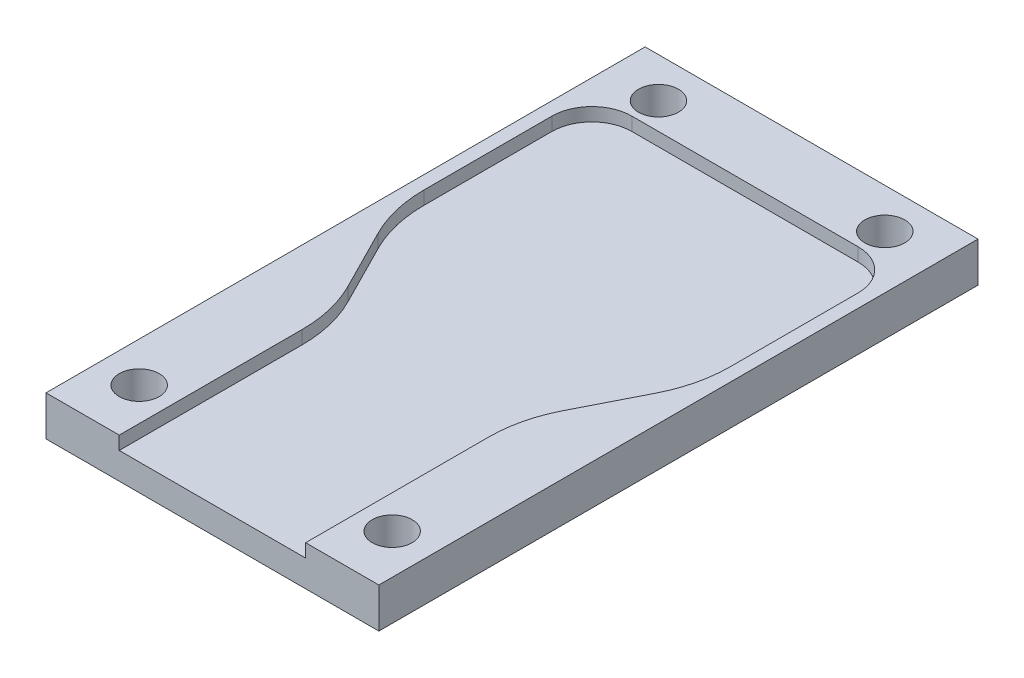
from build123d import *

# Parameters (mm, degrees)
SKETCH1_W           = 25
SKETCH1_H           = 45
BOSS_EXTRUDE1_DEPTH = 3
CUT_EXTRUDE1_DEPTH  = 1
SKETCH3_R           = 1.5
CUT_EXTRUDE2_DEPTH  = 4


with BuildPart() as part:
    # Sketch1 → Boss-Extrude1 (new body)
    with BuildSketch(Plane(origin=(0, 0, 0), x_dir=(1, 0, 0), z_dir=(0, 1, 0))):
        with Locations((12.5, 22.5)):
            Rectangle(SKETCH1_W, SKETCH1_H)
    extrude(amount=BOSS_EXTRUDE1_DEPTH)

    # Sketch2 → Cut-Extrude1 (cut)
    with BuildSketch(Plane(origin=(0, 3, 0), x_dir=(1, 0, 0), z_dir=(0, 1, 0))):
        with BuildLine():
            Line((4, 40), (21, 40))
            ThreePointArc((21, 40), (23.121320344, 39.121320344), (24, 37))
            Line((24, 37), (24, 27.390411508))
            ThreePointArc((24, 27.390411508), (23.725985305, 25.065500788), (22.918958029, 22.868002009))
            Line((22.918958029, 22.868002009), (20.581041971, 18.257235294))
            ThreePointArc((20.581041971, 18.257235294), (19.774014695, 16.059736514), (19.5, 13.734825794))
            Line((19.5, 13.734825794), (19.5, 0))
            Line((19.5, 0), (5.5, 0))
            Line((5.5, 0), (5.5, 13.734825794))
            ThreePointArc((5.5, 13.734825794), (5.225985305, 16.059736514), (4.418958029, 18.257235294))
            Line((4.418958029, 18.257235294), (2.081041971, 22.868002009))
            ThreePointArc((2.081041971, 22.868002009), (1.274014695, 25.065500788), (1, 27.390411508))
            Line((1, 27.390411508), (1, 37))
            ThreePointArc((1, 37), (1.878679656, 39.121320344), (4, 40))
        make_face()
    extrude(amount=-CUT_EXTRUDE1_DEPTH, mode=Mode.SUBTRACT)

    # Sketch3 → Cut-Extrude2 (cut, through all)
    with BuildSketch(Plane(origin=(0, 3, 0), x_dir=(1, 0, 0), z_dir=(0, 1, 0))):
        with Locations((21, 42)):
            Circle(SKETCH3_R)
        with Locations((4, 42)):
            Circle(SKETCH3_R)
        with Locations((3, 4)):
            Circle(SKETCH3_R)
        with Locations((22, 4)):
            Circle(SKETCH3_R)
    extrude(amount=-CUT_EXTRUDE2_DEPTH, mode=Mode.SUBTRACT)


solid = part.part
